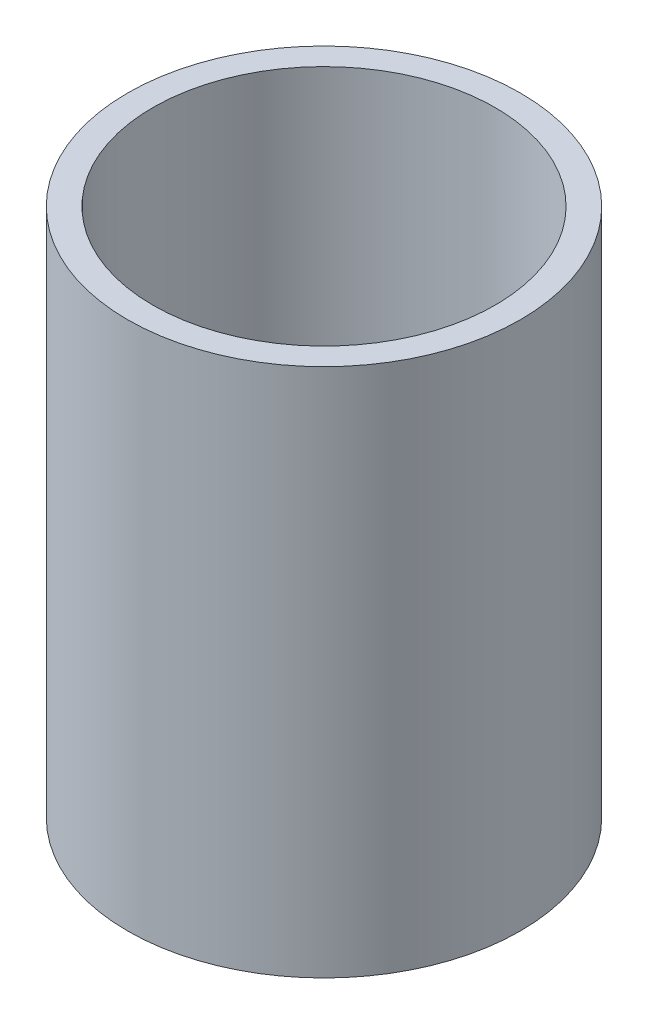
from build123d import *

# Parameters (mm, degrees)
SKETCH1_W = 6.35
SKETCH1_H = 133.35


with BuildPart() as part:
    # Sketch1 → Revolve1 (revolve)
    with BuildSketch(Plane.XY):
        with Locations((-46.2915, -21.057365567)):
            Rectangle(SKETCH1_W, SKETCH1_H)
    revolve(axis=Axis((0, 55, 0), (0, -1, 0)))


solid = part.part
